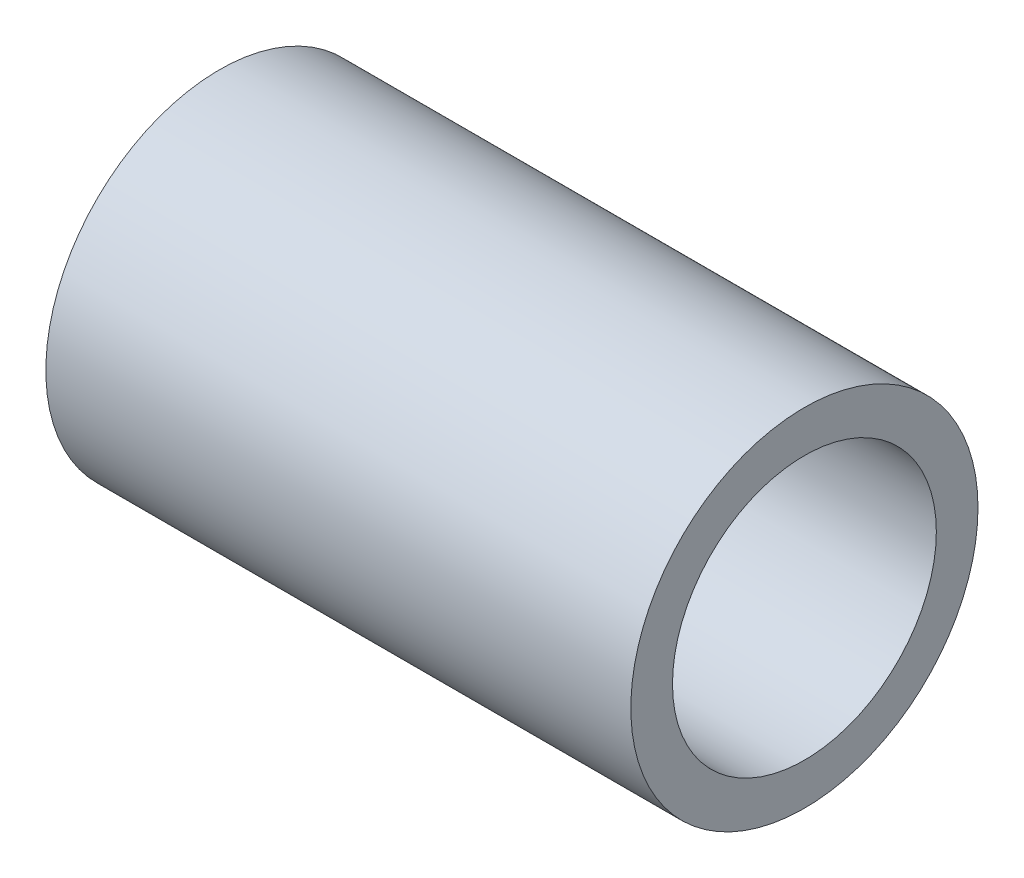
from build123d import *

# Parameters (mm, degrees)
SKETCH1_R           = 6.35
SKETCH1_R_2         = 4.826
BOSS_EXTRUDE1_DEPTH = 21.3995


with BuildPart() as part:
    # Sketch1 → Boss-Extrude1 (new body)
    with BuildSketch(Plane(origin=(0, 0, 0), x_dir=(0, 0, -1), z_dir=(1, 0, 0))):
        Circle(SKETCH1_R)
        Circle(SKETCH1_R_2, mode=Mode.SUBTRACT)
    extrude(amount=BOSS_EXTRUDE1_DEPTH)


solid = part.part
